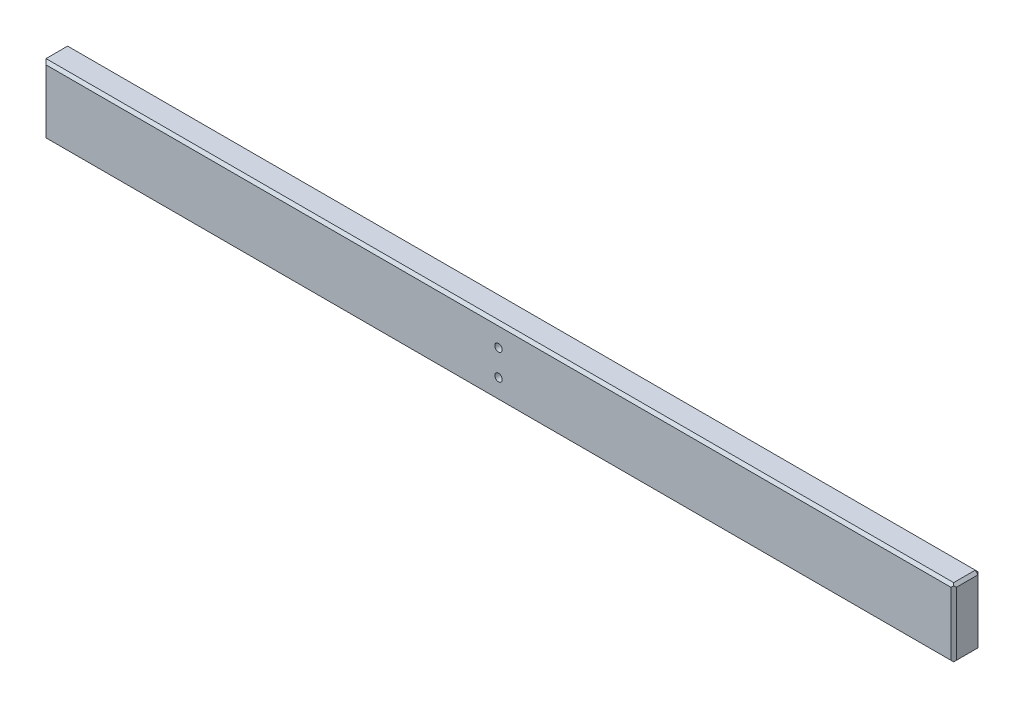
from build123d import *

# Parameters (mm, degrees)
CROQUIS1_W              = 673.4
CROQUIS1_H              = 50.8
SALIENTE_EXTRUIR1_DEPTH = 20
CROQUIS2_R              = 2.75
CORTAR_EXTRUIR1_DEPTH   = 21
CHAFL_N2_SIZE           = 2
CHAFL_N5_SIZE           = 2


with BuildPart() as part:
    # Croquis1 → Saliente-Extruir1 (new body)
    with BuildSketch(Plane.XY):
        Rectangle(CROQUIS1_W, CROQUIS1_H)
    extrude(amount=SALIENTE_EXTRUIR1_DEPTH)

    # Croquis2 → Cortar-Extruir1 (cut, through all)
    with BuildSketch(Plane(origin=(0, 0, 0), x_dir=(-1, 0, 0), z_dir=(0, 0, -1))):
        with Locations((0, 9.55)):
            Circle(CROQUIS2_R)
        with Locations((0, -9.55)):
            Circle(CROQUIS2_R)
    extrude(amount=-CORTAR_EXTRUIR1_DEPTH, mode=Mode.SUBTRACT)

    # Chaflán2
    chafl_n2_edges = [part.edges().sort_by_distance(p)[0] for p in [
        (336.7, 0, 20),
        (0, -25.4, 0),
        (-336.7, 0, 0),
        (0, 25.4, 0),
        (336.7, 0, 0),
        (336.7, -25.4, 10),
        (336.7, 25.4, 10),
    ]]
    chamfer(chafl_n2_edges, length=CHAFL_N2_SIZE)

    # Chaflán5
    chafl_n5_edges = [part.edges().sort_by_distance(p)[0] for p in [
        (-336.7, 0, 20),
        (-1, -25.4, 20),
        (-1, 25.4, 20),
    ]]
    chamfer(chafl_n5_edges, length=CHAFL_N5_SIZE)


solid = part.part
